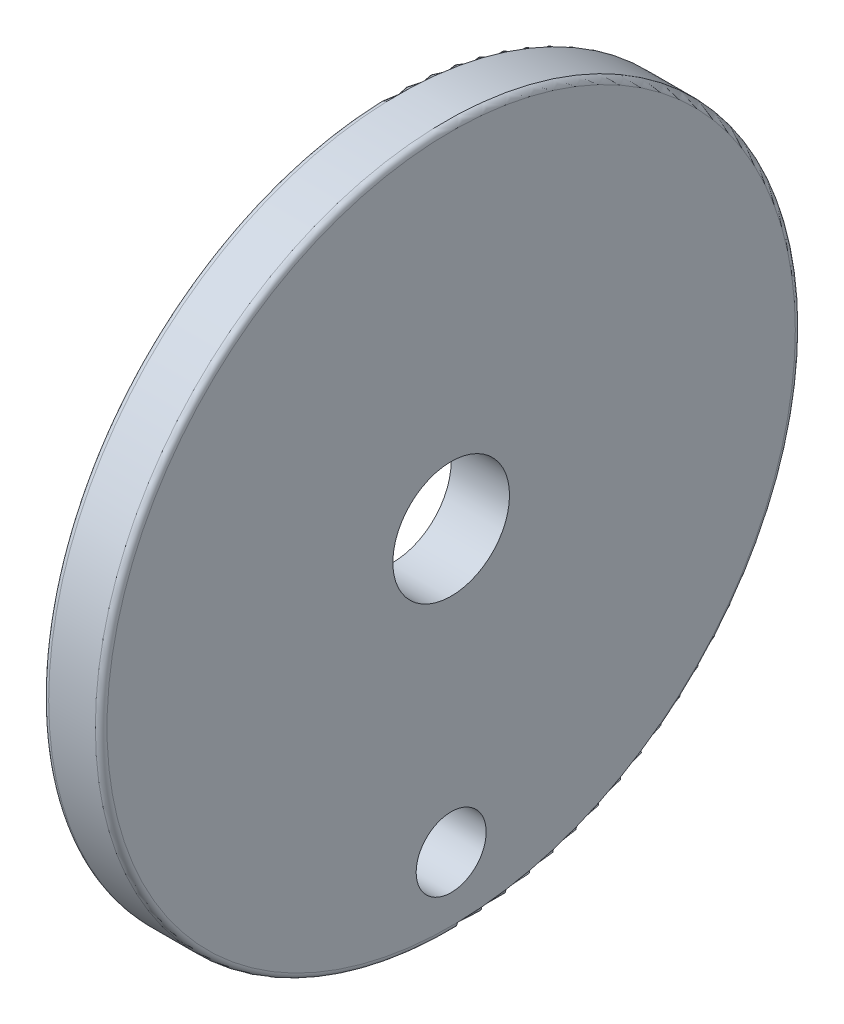
from build123d import *

# Parameters (mm, degrees)
SKICA1_R                 = 30
SKICA1_R_2               = 5
P_IDAT_VYSUNUT_M1_DEPTH  = 5
ODEBRAT_VYSUNUT_M1_REACH = 7
SKICA2_R                 = 3
ZAOBLIT1_R               = 0.5


with BuildPart() as part:
    # Skica1 → Přidat vysunutím1 (new body)
    with BuildSketch(Plane(origin=(0, 0, 0), x_dir=(0, 0, -1), z_dir=(1, 0, 0))):
        Circle(SKICA1_R)
        Circle(SKICA1_R_2, mode=Mode.SUBTRACT)
    extrude(amount=P_IDAT_VYSUNUT_M1_DEPTH)

    # Skica2 → Odebrat vysunutím1 (cut, up to next)
    with BuildSketch(Plane.ZY, mode=Mode.PRIVATE) as odebrat_vysunut_m1_sk1:
        with Locations((0, -24)):
            Circle(SKICA2_R)
    odebrat_vysunut_m1_tool1 = extrude(odebrat_vysunut_m1_sk1.sketch, amount=-ODEBRAT_VYSUNUT_M1_REACH, mode=Mode.PRIVATE) & part.part
    add(odebrat_vysunut_m1_tool1.solids().sort_by_distance((0, -24, 0))[0], mode=Mode.SUBTRACT)

    # Zaoblit1
    zaoblit1_edges = [part.edges().sort_by_distance(p)[0] for p in [
        (0, 0, 30),
        (5, 0, 30),
    ]]
    fillet(zaoblit1_edges, radius=ZAOBLIT1_R)


solid = part.part
